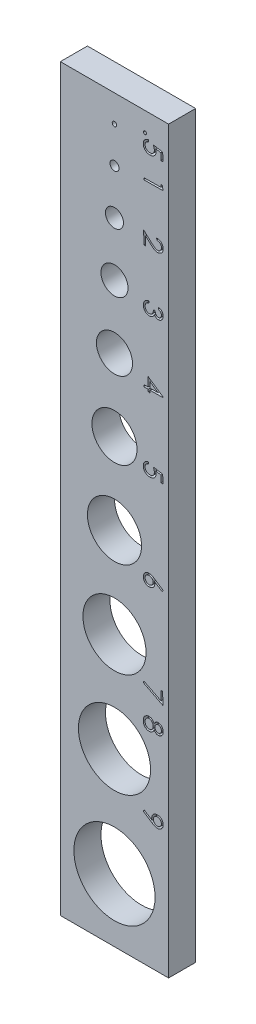
from build123d import *

# Parameters (mm, degrees)
SKETCH1_W           = 12
SKETCH1_H           = 82
SKETCH1_R           = 4.5
SKETCH1_R_2         = 4
SKETCH1_R_3         = 3.5
SKETCH1_R_4         = 3
SKETCH1_R_5         = 1
SKETCH1_R_6         = 1.5
SKETCH1_R_7         = 2
SKETCH1_R_8         = 2.5
SKETCH1_R_9         = 0.5
SKETCH1_R_10        = 0.25
BOSS_EXTRUDE1_DEPTH = 3
CUT_EXTRUDE1_DEPTH  = 0.6


with BuildPart() as part:
    # Sketch1 → Boss-Extrude1 (new body)
    with BuildSketch(Plane.XY):
        with Locations((0, 34)):
            Rectangle(SKETCH1_W, SKETCH1_H)
        Circle(SKETCH1_R, mode=Mode.SUBTRACT)
        with Locations((0, 12)):
            Circle(SKETCH1_R_2, mode=Mode.SUBTRACT)
        with Locations((0, 23)):
            Circle(SKETCH1_R_3, mode=Mode.SUBTRACT)
        with Locations((0, 33)):
            Circle(SKETCH1_R_4, mode=Mode.SUBTRACT)
        with Locations((0, 63)):
            Circle(SKETCH1_R_5, mode=Mode.SUBTRACT)
        with Locations((0, 57)):
            Circle(SKETCH1_R_6, mode=Mode.SUBTRACT)
        with Locations((0, 50)):
            Circle(SKETCH1_R_7, mode=Mode.SUBTRACT)
        with Locations((0, 42)):
            Circle(SKETCH1_R_8, mode=Mode.SUBTRACT)
        with Locations((0, 68)):
            Circle(SKETCH1_R_9, mode=Mode.SUBTRACT)
        with Locations((0, 72)):
            Circle(SKETCH1_R_10, mode=Mode.SUBTRACT)
    extrude(amount=BOSS_EXTRUDE1_DEPTH)

    # Sketch3 → Cut-Extrude1 (cut)
    with BuildSketch(Plane.XY.offset(3)):
        with BuildLine():
            add(Edge.make_bspline(
                [(3.559985776, 72.864336472), (3.559473654, 72.852540956), (3.558469167, 72.829404986), (3.548800443, 72.796162225), (3.532618476, 72.765595711), (3.510294682, 72.738684734), (3.483776229, 72.715488813), (3.453269236, 72.698742779), (3.419548861, 72.688631973), (3.396104516, 72.68706116), (3.384020899, 72.686251536)],
                knots=[0, 0, 0, 0, 1.01541589, 1.991657755, 2.956876933, 3.979293763, 4.990823792, 5.978341565, 6.958002585, 8, 8, 8, 8], degree=3))
            add(Edge.make_bspline(
                [(3.384020899, 72.686251536), (3.372229175, 72.686769628), (3.349100643, 72.687785825), (3.315618284, 72.697423075), (3.285192003, 72.714035693), (3.257793743, 72.735888634), (3.234866364, 72.762415329), (3.218108018, 72.792587334), (3.207383796, 72.825618026), (3.205864975, 72.848707637), (3.20508794, 72.860520366)],
                knots=[0, 0, 0, 0, 1.019769678, 2.000197364, 2.986113415, 4.005221454, 5.021088609, 6.00212763, 6.977881296, 8, 8, 8, 8], degree=3))
            add(Edge.make_bspline(
                [(3.20508794, 72.860520366), (3.205610705, 72.872309948), (3.206636068, 72.895434278), (3.216171942, 72.928826326), (3.232983251, 72.959121398), (3.255175242, 72.986343404), (3.2821235, 73.009248003), (3.312525771, 73.026009756), (3.345778443, 73.036294028), (3.368824174, 73.03754203), (3.380628805, 73.03818129)],
                knots=[0, 0, 0, 0, 1.018230738, 1.997178855, 2.970846284, 3.996097369, 5.019743876, 6.00999916, 6.980669146, 8, 8, 8, 8], degree=3))
            add(Edge.make_bspline(
                [(3.380628805, 73.03818129), (3.392689679, 73.037623738), (3.416173611, 73.036538119), (3.450248233, 73.027633127), (3.480679543, 73.010904306), (3.50773339, 72.988829099), (3.530605666, 72.962444361), (3.54750724, 72.932346215), (3.557557879, 72.899155801), (3.559163067, 72.876135235), (3.559985776, 72.864336472)],
                knots=[0, 0, 0, 0, 1.041595867, 2.028108969, 3.011593627, 4.01868078, 5.03204268, 6.010662336, 6.980401968, 8, 8, 8, 8], degree=3))
        make_face()
        with BuildLine():
            Line((5.360339676, 71.071190772), (5.159782117, 71.069070713))
            Line((5.159782117, 71.069070713), (5.152149906, 71.819147503))
            Line((5.152149906, 71.819147503), (4.57718997, 71.917518229))
            add(Edge.make_bspline(
                [(4.57718997, 71.917518229), (4.583572299, 71.895261787), (4.595886537, 71.852319603), (4.608840583, 71.78867106), (4.618099968, 71.728534577), (4.619391053, 71.689289995), (4.620015157, 71.670319378)],
                knots=[0, 0, 0, 0, 1.103560417, 2.129239359, 3.095684503, 4, 4, 4, 4], degree=3))
            add(Edge.make_bspline(
                [(4.620015157, 71.670319378), (4.619795844, 71.646828608), (4.619366218, 71.600810955), (4.610433662, 71.533252192), (4.59623696, 71.468740358), (4.5758027, 71.407128418), (4.549000115, 71.348862634), (4.515910986, 71.29375656), (4.477352857, 71.241456762), (4.432922749, 71.192962813), (4.383838098, 71.148851338), (4.330786201, 71.110306344), (4.274391197, 71.077167989), (4.214342277, 71.050713248), (4.151150207, 71.029140071), (4.084343076, 71.014083045), (4.014082673, 71.004631966), (3.966077545, 71.002939807), (3.941596353, 71.002076856)],
                knots=[0, 0, 0, 0, 1.055584942, 2.067856546, 3.057852866, 4.02263537, 4.981074008, 5.935965363, 6.908463748, 7.898256009, 8.888497145, 9.871243948, 10.842557664, 11.824152746, 12.817082878, 13.840882629, 14.898914155, 16, 16, 16, 16], degree=3))
            add(Edge.make_bspline(
                [(3.941596353, 71.002076856), (3.924482948, 71.002095453), (3.890481988, 71.002132402), (3.840125962, 71.006837637), (3.790608147, 71.013221189), (3.742316169, 71.023812543), (3.694675593, 71.036118507), (3.648560801, 71.052587907), (3.603192379, 71.071100487), (3.559439816, 71.093238557), (3.517216351, 71.117475196), (3.477613843, 71.144539125), (3.440057838, 71.173206592), (3.405504863, 71.204719853), (3.373011753, 71.237814972), (3.343194042, 71.273309906), (3.315733707, 71.310777384), (3.29104409, 71.350519901), (3.26895593, 71.391972266), (3.249952178, 71.435437908), (3.233374874, 71.480275849), (3.219673571, 71.526860739), (3.209207336, 71.57505727), (3.201569823, 71.624759969), (3.196881508, 71.67602881), (3.195857339, 71.710732418), (3.195335669, 71.728408988)],
                knots=[0, 0, 0, 0, 1.054987957, 2.096052855, 3.116882366, 4.132487153, 5.143291418, 6.149612156, 7.150138838, 8.163796155, 9.171588482, 10.150848618, 11.120359196, 12.083262616, 13.032653721, 13.979198791, 14.939968832, 15.895464126, 16.862620186, 17.834518678, 18.819157809, 19.809492103, 20.826928595, 21.858901691, 22.909413833, 24, 24, 24, 24], degree=3))
            add(Edge.make_bspline(
                [(3.195335669, 71.728408988), (3.195522252, 71.749346634), (3.195890172, 71.790633379), (3.202949564, 71.851188956), (3.214287503, 71.909406256), (3.230811592, 71.965107392), (3.25259468, 72.018267445), (3.279042301, 72.069137026), (3.310384881, 72.11744664), (3.346638493, 72.162840586), (3.386498892, 72.205002572), (3.430058652, 72.24290138), (3.476267263, 72.276473296), (3.52551215, 72.305610981), (3.577706825, 72.330059369), (3.632840783, 72.350552349), (3.690821736, 72.366848981), (3.7309281, 72.373687729), (3.751215077, 72.377146969)],
                knots=[0, 0, 0, 0, 1.070972595, 2.111840699, 3.114818353, 4.103530266, 5.080101137, 6.050733228, 7.033872496, 8.022372693, 9.020119659, 9.999339207, 10.97311987, 11.939537908, 12.923235862, 13.918882858, 14.94730986, 16, 16, 16, 16], degree=3))
            Line((3.751215077, 72.377146969), (3.753335135, 72.160900975))
            add(Edge.make_bspline(
                [(3.753335135, 72.160900975), (3.733996609, 72.156359076), (3.696622026, 72.14758118), (3.644389364, 72.128298406), (3.597402008, 72.105546412), (3.556266979, 72.077683281), (3.520126776, 72.045136248), (3.487557759, 72.008483177), (3.459173004, 71.966603954), (3.435021213, 71.920727656), (3.414716195, 71.87238208), (3.401612575, 71.821789724), (3.392306417, 71.770307544), (3.391871736, 71.73537716), (3.391653111, 71.717808694)],
                knots=[0, 0, 0, 0, 1.144989025, 2.212861912, 3.204660976, 4.149923952, 5.068073888, 6.003830099, 6.971748136, 7.978449302, 8.991371539, 9.988218299, 10.988161226, 12, 12, 12, 12], degree=3))
            add(Edge.make_bspline(
                [(3.391653111, 71.717808694), (3.392265248, 71.700814861), (3.393475986, 71.667203005), (3.401840487, 71.617916411), (3.414605756, 71.570487598), (3.431926236, 71.524868505), (3.454683119, 71.481275841), (3.482489198, 71.439689769), (3.514765638, 71.399591644), (3.551926899, 71.362190008), (3.592670273, 71.328113774), (3.636300159, 71.298244289), (3.682091488, 71.272506916), (3.730715618, 71.252292121), (3.78151493, 71.236425502), (3.834776769, 71.225512308), (3.890407191, 71.218985237), (3.928292637, 71.218545943), (3.947532518, 71.21832285)],
                knots=[0, 0, 0, 0, 0.979540268, 1.937418442, 2.874409727, 3.808170793, 4.744878549, 5.703172589, 6.688222488, 7.708148336, 8.737955377, 9.746060629, 10.752847579, 11.760821078, 12.776342588, 13.816766973, 14.891259097, 16, 16, 16, 16], degree=3))
            add(Edge.make_bspline(
                [(3.947532518, 71.21832285), (3.964939593, 71.218854068), (3.999038878, 71.219894689), (4.048733449, 71.226778907), (4.095887191, 71.237815327), (4.140408443, 71.253187007), (4.182856137, 71.272150966), (4.222228783, 71.296058757), (4.259086181, 71.323989702), (4.293399886, 71.355602335), (4.324138567, 71.391094212), (4.351028379, 71.42944038), (4.373722873, 71.470481178), (4.391981388, 71.514435581), (4.405962111, 71.561203905), (4.415501473, 71.610783501), (4.421823179, 71.662946417), (4.421941355, 71.698708822), (4.422001668, 71.71696067)],
                knots=[0, 0, 0, 0, 1.077209627, 2.110180982, 3.098908156, 4.069869628, 5.021126826, 5.970733619, 6.913709901, 7.879337357, 8.852817336, 9.813798029, 10.773025398, 11.749370118, 12.753951102, 13.788402889, 14.871280215, 16, 16, 16, 16], degree=3))
            add(Edge.make_bspline(
                [(4.422001668, 71.71696067), (4.421551661, 71.732949755), (4.420628901, 71.765736073), (4.41420927, 71.815974668), (4.404859881, 71.86860931), (4.392178005, 71.923717838), (4.375470265, 71.981135432), (4.354918686, 72.040857072), (4.33132318, 72.103150985), (4.313333775, 72.144995953), (4.304126401, 72.166413128)],
                knots=[0, 0, 0, 0, 0.82039401, 1.682253874, 2.595674679, 3.563349206, 4.582547937, 5.662859499, 6.803800105, 8, 8, 8, 8], degree=3))
            Line((4.304126401, 72.166413128), (5.351011417, 71.982816039))
            Line((5.351011417, 71.982816039), (5.360339676, 71.071190772))
        make_face()
        Polygon((5.351011417, 68.71368543), (5.355675547, 68.29984996), (3.250457197, 68.277801349), (3.247913127, 68.486839143), (5.147061765, 68.506767695), (5.143669671, 68.837496862), align=None)
        with BuildLine():
            Line((4.689129072, 63.211284923), (4.687009013, 63.413114517))
            add(Edge.make_bspline(
                [(4.687009013, 63.413114517), (4.712492521, 63.412199779), (4.762544927, 63.410403135), (4.835663206, 63.399237858), (4.905652955, 63.383541302), (4.972041819, 63.360807154), (5.035048837, 63.332457165), (5.094553676, 63.297728467), (5.150427802, 63.256992681), (5.20248725, 63.210804629), (5.249736019, 63.160347227), (5.291080338, 63.106142114), (5.326528274, 63.049173474), (5.355649741, 62.988946547), (5.377916254, 62.925559241), (5.394670092, 62.859334882), (5.404991425, 62.790135934), (5.406593297, 62.742928), (5.40740498, 62.719007278)],
                knots=[0, 0, 0, 0, 1.097505228, 2.155620766, 3.180481467, 4.183502039, 5.172531654, 6.151940074, 7.14558685, 8.146110156, 9.145410305, 10.118288251, 11.077875388, 12.030874005, 12.993642263, 13.966672578, 14.96969315, 16, 16, 16, 16], degree=3))
            add(Edge.make_bspline(
                [(5.40740498, 62.719007278), (5.407144846, 62.695379427), (5.406635389, 62.6491057), (5.398303006, 62.581251674), (5.384545262, 62.516716439), (5.364470271, 62.455607705), (5.338533834, 62.397987217), (5.306450823, 62.3439857), (5.268996711, 62.292965771), (5.225454537, 62.246503594), (5.178092768, 62.204395419), (5.128592174, 62.166793423), (5.076610485, 62.13519053), (5.022205379, 62.109650621), (4.965866449, 62.08928838), (4.9072796, 62.074226418), (4.846568528, 62.065281213), (4.805337082, 62.063805661), (4.784531716, 62.063061098)],
                knots=[0, 0, 0, 0, 1.121975871, 2.197322375, 3.241843777, 4.252685748, 5.247518712, 6.237990346, 7.231893591, 8.248784834, 9.257080656, 10.240217477, 11.198428951, 12.141675047, 13.091211108, 14.040770916, 15.011374074, 16, 16, 16, 16], degree=3))
            add(Edge.make_bspline(
                [(4.784531716, 62.063061098), (4.755063107, 62.063659044), (4.696697855, 62.06484333), (4.610525803, 62.080989198), (4.527074025, 62.106843297), (4.459225435, 62.137510176), (4.405010353, 62.169441863), (4.359901169, 62.197541504), (4.312231496, 62.232019186), (4.260335061, 62.270537878), (4.204881008, 62.314194734), (4.146138855, 62.36307198), (4.083500557, 62.416449863), (4.041419083, 62.454590092), (4.019614516, 62.474352497)],
                knots=[0, 0, 0, 0, 1.188659153, 2.354247174, 3.525968885, 4.71123792, 5.350572219, 6.066366127, 6.856666887, 7.725444904, 8.67666411, 9.706437064, 10.811587574, 12, 12, 12, 12], degree=3))
            Line((4.019614516, 62.474352497), (3.448894697, 62.992070847))
            Line((3.448894697, 62.992070847), (3.459070979, 62.020235911))
            Line((3.459070979, 62.020235911), (3.25596935, 62.018115852))
            Line((3.25596935, 62.018115852), (3.241128939, 63.44788348))
            Line((3.241128939, 63.44788348), (4.118409254, 62.652437433))
            add(Edge.make_bspline(
                [(4.118409254, 62.652437433), (4.1397332, 62.633196124), (4.18068141, 62.596247185), (4.239933208, 62.543350475), (4.2955553, 62.496375087), (4.346792036, 62.454474321), (4.39333777, 62.417406314), (4.435714882, 62.385724611), (4.474288618, 62.360048201), (4.51896422, 62.332174491), (4.573556354, 62.305773276), (4.640115562, 62.282993365), (4.708489629, 62.269274149), (4.754648695, 62.268048233), (4.777747528, 62.267434762)],
                knots=[0, 0, 0, 0, 1.320781117, 2.536285893, 3.652249599, 4.66835783, 5.579870562, 6.388409538, 7.100439732, 7.710169797, 8.808929471, 9.87974959, 10.938988219, 12, 12, 12, 12], degree=3))
            add(Edge.make_bspline(
                [(4.777747528, 62.267434762), (4.792335951, 62.267956412), (4.82110416, 62.2689851), (4.863231445, 62.276156372), (4.904043654, 62.286497755), (4.94274092, 62.302063724), (4.98038961, 62.320700057), (5.015823346, 62.344424262), (5.050412547, 62.371348862), (5.082289867, 62.402827897), (5.111736633, 62.436781773), (5.137928794, 62.472909193), (5.159448472, 62.511125051), (5.177081413, 62.551025746), (5.190655356, 62.592804188), (5.200359333, 62.636371544), (5.206107101, 62.681820459), (5.206316612, 62.712630315), (5.20642341, 62.728335537)],
                knots=[0, 0, 0, 0, 0.999925116, 1.971841423, 2.92388823, 3.881345835, 4.826212886, 5.799288192, 6.799776752, 7.827815551, 8.865358063, 9.879321666, 10.881873478, 11.866892925, 12.866019285, 13.888837022, 14.923841643, 16, 16, 16, 16], degree=3))
            add(Edge.make_bspline(
                [(5.20642341, 62.728335537), (5.205884047, 62.744754108), (5.204819337, 62.777164656), (5.19792196, 62.824597871), (5.18694147, 62.869934964), (5.171474124, 62.912867936), (5.152494402, 62.954028294), (5.128575389, 62.992518079), (5.100651172, 63.028929776), (5.06902234, 63.063176517), (5.033476821, 63.094600045), (4.994092536, 63.122199401), (4.951599955, 63.146548026), (4.905451252, 63.166790418), (4.856273061, 63.183781631), (4.803647633, 63.196957998), (4.747610784, 63.206215598), (4.708945865, 63.209567159), (4.689129072, 63.211284923)],
                knots=[0, 0, 0, 0, 1.000324658, 1.974658513, 2.914587732, 3.837998796, 4.751071336, 5.671264089, 6.592785758, 7.543463651, 8.507543491, 9.477643496, 10.468918963, 11.486736481, 12.543450846, 13.635848679, 14.78830998, 16, 16, 16, 16], degree=3))
        make_face()
        with BuildLine():
            Line((4.861701855, 56.651399105), (4.859157785, 56.866373064))
            add(Edge.make_bspline(
                [(4.859157785, 56.866373064), (4.880436879, 56.861444152), (4.921970126, 56.851823737), (4.981824936, 56.832593521), (5.037754482, 56.809499206), (5.090494812, 56.783989509), (5.139152148, 56.754374239), (5.18425187, 56.721788551), (5.225606747, 56.685625583), (5.262781746, 56.646062145), (5.296424673, 56.604293746), (5.325215504, 56.559950386), (5.350034436, 56.513919186), (5.370555343, 56.465872697), (5.38612071, 56.415654578), (5.397529634, 56.363745774), (5.405090997, 56.310005692), (5.40606329, 56.273488951), (5.406556957, 56.254948117)],
                knots=[0, 0, 0, 0, 1.173306688, 2.290099197, 3.373202571, 4.422689437, 5.434686452, 6.429671004, 7.409144712, 8.381497029, 9.343383221, 10.28704873, 11.218038754, 12.150421619, 13.089584196, 14.038521706, 15.004088426, 16, 16, 16, 16], degree=3))
            add(Edge.make_bspline(
                [(5.406556957, 56.254948117), (5.405965115, 56.227898578), (5.404795728, 56.174452889), (5.391138901, 56.095505638), (5.368210139, 56.019325398), (5.335947567, 55.946672706), (5.296254903, 55.879248905), (5.249054781, 55.819076523), (5.195301276, 55.766768197), (5.13515833, 55.723483586), (5.071438637, 55.688715047), (5.0054749, 55.663357643), (4.937787409, 55.64736982), (4.891891392, 55.645089166), (4.868910055, 55.643947182)],
                knots=[0, 0, 0, 0, 1.077726037, 2.129419264, 3.183224812, 4.243087324, 5.291876736, 6.295389808, 7.283912331, 8.272643719, 9.24111859, 10.170628242, 11.083985668, 12, 12, 12, 12], degree=3))
            add(Edge.make_bspline(
                [(4.868910055, 55.643947182), (4.846796644, 55.644397634), (4.803332941, 55.645282994), (4.740030405, 55.658279188), (4.679985624, 55.678553501), (4.623332068, 55.707765713), (4.570611116, 55.745917246), (4.521369106, 55.792516864), (4.47540958, 55.847234249), (4.449098541, 55.888555941), (4.435570044, 55.909802551)],
                knots=[0, 0, 0, 0, 0.991619515, 1.949018852, 2.888551481, 3.831167361, 4.80011465, 5.801621388, 6.869647158, 8, 8, 8, 8], degree=3))
            add(Edge.make_bspline(
                [(4.435570044, 55.909802551), (4.425084084, 55.88514096), (4.404468127, 55.836654959), (4.362192553, 55.770775203), (4.314628564, 55.710315373), (4.276806533, 55.676238024), (4.25790912, 55.659211605)],
                knots=[0, 0, 0, 0, 1.034722232, 2.034319016, 3.017866478, 4, 4, 4, 4], degree=3))
            add(Edge.make_bspline(
                [(4.25790912, 55.659211605), (4.243939355, 55.648107564), (4.216461747, 55.626266648), (4.172837021, 55.597646801), (4.128036776, 55.573446643), (4.081678247, 55.553829993), (4.034211382, 55.538076138), (3.985425718, 55.526548234), (3.935279476, 55.519736521), (3.901476272, 55.518312802), (3.884354767, 55.51759168)],
                knots=[0, 0, 0, 0, 1.050262654, 2.065797339, 3.067324926, 4.044175813, 5.025729501, 6.008728387, 6.991410217, 8, 8, 8, 8], degree=3))
            add(Edge.make_bspline(
                [(3.884354767, 55.51759168), (3.854730777, 55.518428833), (3.795689348, 55.520097303), (3.708448276, 55.53799134), (3.623215716, 55.566588217), (3.541075692, 55.606712719), (3.464363606, 55.657087667), (3.395628131, 55.717067857), (3.336311972, 55.786008325), (3.286309595, 55.862871796), (3.246208942, 55.946477238), (3.218073553, 56.036039841), (3.19946632, 56.130237073), (3.197008711, 56.194931672), (3.195759681, 56.227811365)],
                knots=[0, 0, 0, 0, 0.966694564, 1.92664895, 2.896261802, 3.897893656, 4.904558281, 5.886300644, 6.86849902, 7.866238128, 8.874183463, 9.887666857, 10.926450323, 12, 12, 12, 12], degree=3))
            add(Edge.make_bspline(
                [(3.195759681, 56.227811365), (3.195934852, 56.250021023), (3.196278278, 56.293563552), (3.203425064, 56.357489561), (3.214657201, 56.418819987), (3.231162383, 56.477492438), (3.252932595, 56.533203709), (3.279319569, 56.586244413), (3.310848334, 56.636257668), (3.346863979, 56.683681368), (3.388308652, 56.727159936), (3.43364498, 56.767950081), (3.484545623, 56.803874367), (3.539790475, 56.836094399), (3.599500739, 56.86457286), (3.663798056, 56.88930292), (3.73298957, 56.909419773), (3.780970437, 56.919936611), (3.805488581, 56.925310697)],
                knots=[0, 0, 0, 0, 1.046149723, 2.050999747, 3.026929888, 3.982181198, 4.918596996, 5.842082274, 6.769881807, 7.701166001, 8.64362752, 9.596762996, 10.57089557, 11.573977735, 12.607839967, 13.685330975, 14.817207988, 16, 16, 16, 16], degree=3))
            Line((3.805488581, 56.925310697), (3.80760864, 56.719240986))
            add(Edge.make_bspline(
                [(3.80760864, 56.719240986), (3.791168254, 56.71444058), (3.759193187, 56.705104223), (3.713251449, 56.689044778), (3.6709446, 56.671278964), (3.63203517, 56.652212387), (3.596857153, 56.631533126), (3.565329809, 56.60931554), (3.536876357, 56.586128858), (3.520520347, 56.568758219), (3.51249646, 56.560236579)],
                knots=[0, 0, 0, 0, 1.209971331, 2.353285215, 3.43640071, 4.450177468, 5.412687175, 6.315866345, 7.173802289, 8, 8, 8, 8], degree=3))
            add(Edge.make_bspline(
                [(3.51249646, 56.560236579), (3.503341082, 56.549115164), (3.485131542, 56.526995288), (3.462235104, 56.490428016), (3.442720356, 56.451988803), (3.426943942, 56.411194877), (3.414569018, 56.368369209), (3.406289615, 56.323051847), (3.400962637, 56.275712882), (3.400693782, 56.243373357), (3.400557357, 56.226963341)],
                knots=[0, 0, 0, 0, 0.960555306, 1.910491269, 2.872342621, 3.834055196, 4.825292892, 5.842842975, 6.905395783, 8, 8, 8, 8], degree=3))
            add(Edge.make_bspline(
                [(3.400557357, 56.226963341), (3.401028536, 56.208277058), (3.401949549, 56.171750955), (3.409641819, 56.118638213), (3.420189694, 56.068207202), (3.43633712, 56.020990191), (3.455509212, 55.976062192), (3.480022698, 55.93453567), (3.508152782, 55.895396297), (3.540653007, 55.859792216), (3.57594697, 55.827787703), (3.613213571, 55.800155425), (3.651342247, 55.776020509), (3.691356564, 55.756878149), (3.732853366, 55.742592975), (3.775465479, 55.731663118), (3.819734875, 55.72574634), (3.849711076, 55.725206212), (3.864850226, 55.724933427)],
                knots=[0, 0, 0, 0, 1.173759928, 2.29435017, 3.367680958, 4.407023928, 5.425313666, 6.432383096, 7.430954561, 8.449747856, 9.455994245, 10.420684121, 11.362276694, 12.288023167, 13.201067594, 14.116700998, 15.048860564, 16, 16, 16, 16], degree=3))
            add(Edge.make_bspline(
                [(3.864850226, 55.724933427), (3.885139781, 55.726011884), (3.925458589, 55.728154963), (3.984575589, 55.742351397), (4.041652165, 55.764488776), (4.095503118, 55.795601744), (4.145440568, 55.833317337), (4.189103928, 55.878039092), (4.226318373, 55.928270552), (4.251180665, 55.975284711), (4.268115632, 56.016563343), (4.278824036, 56.052176293), (4.289174738, 56.09140666), (4.297378659, 56.134803918), (4.30462847, 56.18203468), (4.310429864, 56.233245268), (4.315143962, 56.28852865), (4.317103619, 56.326739897), (4.318118789, 56.346534656)],
                knots=[0, 0, 0, 0, 1.127643216, 2.240819507, 3.362973506, 4.520875543, 5.687040538, 6.831721848, 7.983742915, 9.150887069, 9.778347085, 10.461812224, 11.216548265, 12.033326562, 12.915734579, 13.872895481, 14.898085661, 16, 16, 16, 16], degree=3))
            Line((4.318118789, 56.346534656), (4.511044136, 56.348654714))
            add(Edge.make_bspline(
                [(4.511044136, 56.348654714), (4.511825846, 56.325011341), (4.513354538, 56.278774981), (4.523941232, 56.211034024), (4.54022386, 56.146594931), (4.562899639, 56.086285567), (4.590814008, 56.032114191), (4.621309622, 55.98425943), (4.656487512, 55.945305375), (4.694581971, 55.913998678), (4.735766926, 55.891420991), (4.778159643, 55.874173537), (4.822707837, 55.864833114), (4.852900263, 55.863720154), (4.868062032, 55.863161258)],
                knots=[0, 0, 0, 0, 1.268875079, 2.481378802, 3.671964755, 4.831691112, 5.931079786, 6.939043712, 7.86841796, 8.736960605, 9.572638348, 10.379936968, 11.186450867, 12, 12, 12, 12], degree=3))
            add(Edge.make_bspline(
                [(4.868062032, 55.863161258), (4.879396514, 55.863596325), (4.90163387, 55.864449892), (4.934238273, 55.870384881), (4.965933014, 55.878632529), (4.996356467, 55.891001001), (5.025468986, 55.906859054), (5.053182163, 55.926220102), (5.079957726, 55.94869145), (5.105118772, 55.974470442), (5.128530088, 56.002559791), (5.148332142, 56.033352362), (5.165515411, 56.06558157), (5.179013832, 56.099787612), (5.189641347, 56.135542953), (5.1973164, 56.172972112), (5.20167146, 56.212299874), (5.20172955, 56.239107538), (5.201759281, 56.252828058)],
                knots=[0, 0, 0, 0, 0.95166413, 1.867089752, 2.777187475, 3.698751812, 4.617865583, 5.556479832, 6.533937407, 7.549793846, 8.578953447, 9.599792997, 10.619458175, 11.642435756, 12.682969136, 13.74939355, 14.848109587, 16, 16, 16, 16], degree=3))
            add(Edge.make_bspline(
                [(5.201759281, 56.252828058), (5.200636688, 56.27482184), (5.198451575, 56.3176325), (5.183232166, 56.379378577), (5.158265654, 56.436066365), (5.129756045, 56.479419151), (5.101798038, 56.511257767), (5.077333922, 56.534329179), (5.049619914, 56.556353708), (5.018669635, 56.577605555), (4.984078243, 56.597432113), (4.946272106, 56.616499024), (4.905199367, 56.634676076), (4.876451102, 56.645728618), (4.861701855, 56.651399105)],
                knots=[0, 0, 0, 0, 1.404109188, 2.733083474, 4.034611119, 5.344034922, 6.028487238, 6.737270714, 7.488689976, 8.287420331, 9.132790347, 10.033057222, 10.990863469, 12, 12, 12, 12], degree=3))
        make_face()
        Polygon((5.411645098, 48.470092348), (5.41206911, 48.427267161), (3.944988447, 48.412002738), (3.947532518, 48.157171675), (3.745702924, 48.155051616), (3.743158853, 48.409882679), (3.253849291, 48.404794538), (3.251729232, 48.615104367), (3.741038794, 48.620192508), (3.730438501, 49.625948384), align=None)
        Polygon((3.942868388, 48.622312567), (4.820148704, 48.631640825), (3.9360842, 49.241793737), align=None, mode=Mode.SUBTRACT)
        with BuildLine():
            Line((5.360339676, 40.135293336), (5.159782117, 40.133173277))
            Line((5.159782117, 40.133173277), (5.152149906, 40.883250067))
            Line((5.152149906, 40.883250067), (4.57718997, 40.981620793))
            add(Edge.make_bspline(
                [(4.57718997, 40.981620793), (4.583572299, 40.959364351), (4.595886537, 40.916422168), (4.608840583, 40.852773624), (4.618099968, 40.792637141), (4.619391053, 40.753392559), (4.620015157, 40.734421942)],
                knots=[0, 0, 0, 0, 1.103560417, 2.129239359, 3.095684503, 4, 4, 4, 4], degree=3))
            add(Edge.make_bspline(
                [(4.620015157, 40.734421942), (4.619795844, 40.710931172), (4.619366218, 40.664913519), (4.610433662, 40.597354756), (4.59623696, 40.532842922), (4.5758027, 40.471230982), (4.549000115, 40.412965198), (4.515910986, 40.357859124), (4.477352857, 40.305559326), (4.432922749, 40.257065377), (4.383838098, 40.212953903), (4.330786201, 40.174408908), (4.274391197, 40.141270553), (4.214342277, 40.114815812), (4.151150207, 40.093242635), (4.084343076, 40.078185609), (4.014082673, 40.068734531), (3.966077545, 40.067042371), (3.941596353, 40.06617942)],
                knots=[0, 0, 0, 0, 1.055584942, 2.067856546, 3.057852866, 4.02263537, 4.981074008, 5.935965363, 6.908463748, 7.898256009, 8.888497145, 9.871243948, 10.842557664, 11.824152746, 12.817082878, 13.840882629, 14.898914155, 16, 16, 16, 16], degree=3))
            add(Edge.make_bspline(
                [(3.941596353, 40.06617942), (3.924482948, 40.066198018), (3.890481988, 40.066234966), (3.840125962, 40.070940201), (3.790608147, 40.077323753), (3.742316169, 40.087915107), (3.694675593, 40.100221071), (3.648560801, 40.116690471), (3.603192379, 40.135203051), (3.559439816, 40.157341121), (3.517216351, 40.18157776), (3.477613843, 40.208641689), (3.440057838, 40.237309156), (3.405504863, 40.268822417), (3.373011753, 40.301917537), (3.343194042, 40.33741247), (3.315733707, 40.374879948), (3.29104409, 40.414622465), (3.26895593, 40.45607483), (3.249952178, 40.499540472), (3.233374874, 40.544378413), (3.219673571, 40.590963303), (3.209207336, 40.639159834), (3.201569823, 40.688862533), (3.196881508, 40.740131374), (3.195857339, 40.774834982), (3.195335669, 40.792511552)],
                knots=[0, 0, 0, 0, 1.054987957, 2.096052855, 3.116882366, 4.132487153, 5.143291418, 6.149612156, 7.150138838, 8.163796155, 9.171588482, 10.150848618, 11.120359196, 12.083262616, 13.032653721, 13.979198791, 14.939968832, 15.895464126, 16.862620186, 17.834518678, 18.819157809, 19.809492103, 20.826928595, 21.858901691, 22.909413833, 24, 24, 24, 24], degree=3))
            add(Edge.make_bspline(
                [(3.195335669, 40.792511552), (3.195522252, 40.813449198), (3.195890172, 40.854735943), (3.202949564, 40.91529152), (3.214287503, 40.97350882), (3.230811592, 41.029209956), (3.25259468, 41.082370009), (3.279042301, 41.13323959), (3.310384881, 41.181549204), (3.346638493, 41.22694315), (3.386498892, 41.269105136), (3.430058652, 41.307003944), (3.476267263, 41.34057586), (3.52551215, 41.369713545), (3.577706825, 41.394161933), (3.632840783, 41.414654913), (3.690821736, 41.430951546), (3.7309281, 41.437790293), (3.751215077, 41.441249533)],
                knots=[0, 0, 0, 0, 1.070972595, 2.111840699, 3.114818353, 4.103530266, 5.080101137, 6.050733228, 7.033872496, 8.022372693, 9.020119659, 9.999339207, 10.97311987, 11.939537908, 12.923235862, 13.918882858, 14.94730986, 16, 16, 16, 16], degree=3))
            Line((3.751215077, 41.441249533), (3.753335135, 41.225003539))
            add(Edge.make_bspline(
                [(3.753335135, 41.225003539), (3.733996609, 41.22046164), (3.696622026, 41.211683744), (3.644389364, 41.19240097), (3.597402008, 41.169648977), (3.556266979, 41.141785845), (3.520126776, 41.109238812), (3.487557759, 41.072585742), (3.459173004, 41.030706518), (3.435021213, 40.98483022), (3.414716195, 40.936484644), (3.401612575, 40.885892288), (3.392306417, 40.834410108), (3.391871736, 40.799479724), (3.391653111, 40.781911258)],
                knots=[0, 0, 0, 0, 1.144989025, 2.212861912, 3.204660976, 4.149923952, 5.068073888, 6.003830099, 6.971748136, 7.978449302, 8.991371539, 9.988218299, 10.988161226, 12, 12, 12, 12], degree=3))
            add(Edge.make_bspline(
                [(3.391653111, 40.781911258), (3.392265248, 40.764917425), (3.393475986, 40.731305569), (3.401840487, 40.682018975), (3.414605756, 40.634590162), (3.431926236, 40.588971069), (3.454683119, 40.545378405), (3.482489198, 40.503792333), (3.514765638, 40.463694208), (3.551926899, 40.426292573), (3.592670273, 40.392216338), (3.636300159, 40.362346853), (3.682091488, 40.33660948), (3.730715618, 40.316394685), (3.78151493, 40.300528066), (3.834776769, 40.289614872), (3.890407191, 40.283087801), (3.928292637, 40.282648507), (3.947532518, 40.282425414)],
                knots=[0, 0, 0, 0, 0.979540268, 1.937418442, 2.874409727, 3.808170793, 4.744878549, 5.703172589, 6.688222488, 7.708148336, 8.737955377, 9.746060629, 10.752847579, 11.760821078, 12.776342588, 13.816766973, 14.891259097, 16, 16, 16, 16], degree=3))
            add(Edge.make_bspline(
                [(3.947532518, 40.282425414), (3.964939593, 40.282956632), (3.999038878, 40.283997253), (4.048733449, 40.290881471), (4.095887191, 40.301917892), (4.140408443, 40.317289571), (4.182856137, 40.33625353), (4.222228783, 40.360161321), (4.259086181, 40.388092266), (4.293399886, 40.419704899), (4.324138567, 40.455196777), (4.351028379, 40.493542944), (4.373722873, 40.534583742), (4.391981388, 40.578538145), (4.405962111, 40.625306469), (4.415501473, 40.674886065), (4.421823179, 40.727048981), (4.421941355, 40.762811386), (4.422001668, 40.781063235)],
                knots=[0, 0, 0, 0, 1.077209627, 2.110180982, 3.098908156, 4.069869628, 5.021126826, 5.970733619, 6.913709901, 7.879337357, 8.852817336, 9.813798029, 10.773025398, 11.749370118, 12.753951102, 13.788402889, 14.871280215, 16, 16, 16, 16], degree=3))
            add(Edge.make_bspline(
                [(4.422001668, 40.781063235), (4.421551661, 40.797052319), (4.420628901, 40.829838637), (4.41420927, 40.880077232), (4.404859881, 40.932711874), (4.392178005, 40.987820402), (4.375470265, 41.045237996), (4.354918686, 41.104959636), (4.33132318, 41.167253549), (4.313333775, 41.209098517), (4.304126401, 41.230515692)],
                knots=[0, 0, 0, 0, 0.82039401, 1.682253874, 2.595674679, 3.563349206, 4.582547937, 5.662859499, 6.803800105, 8, 8, 8, 8], degree=3))
            Line((4.304126401, 41.230515692), (5.351011417, 41.046918603))
            Line((5.351011417, 41.046918603), (5.360339676, 40.135293336))
        make_face()
        with BuildLine():
            Line((5.409525039, 29.918730168), (5.29843396, 29.744461338))
            Line((5.29843396, 29.744461338), (4.430905915, 30.303732839))
            add(Edge.make_bspline(
                [(4.430905915, 30.303732839), (4.436986182, 30.285158351), (4.448892527, 30.24878589), (4.461507081, 30.19419487), (4.469527611, 30.141286305), (4.470926242, 30.106593343), (4.471611043, 30.089606904)],
                knots=[0, 0, 0, 0, 1.07113288, 2.097486466, 3.068487418, 4, 4, 4, 4], degree=3))
            add(Edge.make_bspline(
                [(4.471611043, 30.089606904), (4.471345443, 30.069084729), (4.470821204, 30.028578275), (4.462409463, 29.969074227), (4.448937316, 29.911948128), (4.429657547, 29.857057317), (4.404570315, 29.804518731), (4.373928312, 29.754074609), (4.337025269, 29.706504125), (4.295366146, 29.661478813), (4.249732097, 29.620161294), (4.200492738, 29.584429918), (4.149114049, 29.553597569), (4.094747838, 29.528558828), (4.037801891, 29.508267831), (3.977825496, 29.494772726), (3.915457547, 29.48533917), (3.872942677, 29.48396846), (3.85128185, 29.483270099)],
                knots=[0, 0, 0, 0, 1.018280883, 2.009872138, 2.976790137, 3.929052543, 4.892832391, 5.86300533, 6.854074845, 7.877181731, 8.905930242, 9.905438123, 10.893645607, 11.876479981, 12.873125352, 13.889469418, 14.924709423, 16, 16, 16, 16], degree=3))
            add(Edge.make_bspline(
                [(3.85128185, 29.483270099), (3.821683752, 29.483919411), (3.76336454, 29.485198798), (3.677963686, 29.500280346), (3.597138993, 29.526545701), (3.520875706, 29.56244835), (3.450969225, 29.608805317), (3.387722429, 29.664235967), (3.332082362, 29.728657298), (3.284282794, 29.801021723), (3.245995503, 29.879486229), (3.217710433, 29.961883427), (3.200232601, 30.047472127), (3.197541138, 30.105639376), (3.196183693, 30.134976162)],
                knots=[0, 0, 0, 0, 1.033374691, 2.036130795, 3.016962388, 3.995603178, 4.972248063, 5.938144807, 6.92542083, 7.937679075, 8.96032944, 9.967696499, 10.975003024, 12, 12, 12, 12], degree=3))
            add(Edge.make_bspline(
                [(3.196183693, 30.134976162), (3.196821859, 30.163312808), (3.198088256, 30.219544895), (3.213631819, 30.302170715), (3.238536706, 30.382045429), (3.274930271, 30.457601297), (3.319745183, 30.52857989), (3.374665547, 30.59164154), (3.437621001, 30.647180194), (3.508839087, 30.693199525), (3.585229151, 30.730906418), (3.66532872, 30.758764292), (3.748536112, 30.775747672), (3.804987692, 30.778506116), (3.833473356, 30.779898037)],
                knots=[0, 0, 0, 0, 1.009186099, 2.002659077, 2.986059601, 3.98469603, 4.984247613, 5.970369082, 6.956001077, 7.968001925, 8.984485162, 9.986967225, 10.984216614, 12, 12, 12, 12], degree=3))
            add(Edge.make_bspline(
                [(3.833473356, 30.779898037), (3.855272216, 30.779513588), (3.899634787, 30.7787312), (3.966875496, 30.768722887), (4.035752009, 30.752955836), (4.094141957, 30.73471515), (4.142313926, 30.716186211), (4.18068899, 30.69957545), (4.221283349, 30.680946512), (4.263464784, 30.65924364), (4.307587949, 30.635083607), (4.353430473, 30.608184745), (4.40131112, 30.579080124), (4.433501406, 30.558221535), (4.449986444, 30.547539597)],
                knots=[0, 0, 0, 0, 1.172854459, 2.386860531, 3.651453688, 4.975272331, 5.676275456, 6.429720153, 7.226464736, 8.080737454, 8.983272135, 9.934786162, 10.942378808, 12, 12, 12, 12], degree=3))
            Line((4.449986444, 30.547539597), (5.409525039, 29.918730168))
        make_face()
        with BuildLine():
            add(Edge.make_bspline(
                [(4.286741919, 30.137944244), (4.286168606, 30.152947252), (4.28503857, 30.182519069), (4.278613157, 30.226015396), (4.268008473, 30.267805364), (4.25314197, 30.307721802), (4.234139951, 30.345782638), (4.21185667, 30.382433045), (4.184642702, 30.416967737), (4.154102841, 30.449551222), (4.120922793, 30.479544602), (4.085609312, 30.505659601), (4.048290586, 30.527192928), (4.009857705, 30.545877051), (3.96924678, 30.559128731), (3.927319759, 30.569190515), (3.883511196, 30.57463561), (3.853698235, 30.575225083), (3.838561497, 30.575524372)],
                knots=[0, 0, 0, 0, 1.0339263, 2.037929961, 3.022860678, 3.999669711, 4.966524986, 5.950299568, 6.949616574, 7.989989403, 9.024374228, 10.027480128, 11.009566239, 11.989719108, 12.965945435, 13.946243429, 14.957259787, 16, 16, 16, 16], degree=3))
            add(Edge.make_bspline(
                [(3.838561497, 30.575524372), (3.823558177, 30.574951643), (3.793985744, 30.573822759), (3.750493903, 30.567388954), (3.708687352, 30.556815299), (3.668713015, 30.541789886), (3.630426589, 30.523192584), (3.593991296, 30.50034623), (3.559120779, 30.473602418), (3.52655922, 30.44285373), (3.496498718, 30.409729305), (3.470614763, 30.374427148), (3.448604807, 30.337560644), (3.431022559, 30.298943292), (3.416490394, 30.258815596), (3.407625018, 30.216701106), (3.401796821, 30.17316187), (3.401255991, 30.143617842), (3.400981369, 30.128615986)],
                knots=[0, 0, 0, 0, 1.035379192, 2.040793697, 3.027108457, 4.00529012, 4.982255714, 5.959123956, 6.967560851, 8.00939563, 9.045233991, 10.049749474, 11.02481497, 12.002218523, 12.973766386, 13.962777315, 14.965539756, 16, 16, 16, 16], degree=3))
            add(Edge.make_bspline(
                [(3.400981369, 30.128615986), (3.401557197, 30.11361376), (3.402692188, 30.084043484), (3.409081489, 30.040535925), (3.419807534, 29.998834716), (3.434202621, 29.958689793), (3.452856408, 29.920363711), (3.476199552, 29.884156154), (3.502894378, 29.849306786), (3.533219175, 29.816469853), (3.56638337, 29.786591003), (3.601708682, 29.760525688), (3.638877319, 29.738782306), (3.677550997, 29.721057815), (3.717693265, 29.706550121), (3.759803786, 29.697678078), (3.803344093, 29.691851681), (3.832887974, 29.691310605), (3.847889756, 29.691035857)],
                knots=[0, 0, 0, 0, 1.035146541, 2.040335127, 3.02642826, 4.001030843, 4.977776911, 5.959619206, 6.967829503, 8.002792361, 9.038397967, 10.042687733, 11.025932903, 12.003116832, 12.974446386, 13.963235082, 14.965772201, 16, 16, 16, 16], degree=3))
            add(Edge.make_bspline(
                [(3.847889756, 29.691035857), (3.863034546, 29.691602231), (3.892748814, 29.692713463), (3.936520385, 29.699196479), (3.978393509, 29.709790045), (4.018678117, 29.724241077), (4.057036995, 29.743053824), (4.093534354, 29.765976753), (4.128058266, 29.79311938), (4.160906693, 29.82324645), (4.190744137, 29.856450347), (4.216878265, 29.891740555), (4.238423063, 29.929060178), (4.256984806, 29.967391186), (4.270505451, 30.007919779), (4.280291118, 30.04977595), (4.285875149, 30.093411926), (4.286450014, 30.122946956), (4.286741919, 30.137944244)],
                knots=[0, 0, 0, 0, 1.043393225, 2.047150523, 3.041276387, 4.014491233, 4.989846512, 5.97852245, 6.977594245, 8.011083419, 9.045214426, 10.048074184, 11.029919311, 12.00983167, 12.976596784, 13.966135232, 14.967244838, 16, 16, 16, 16], degree=3))
        make_face(mode=Mode.SUBTRACT)
        Polygon((5.347619323, 20.199532786), (5.361611711, 18.864319778), (3.191519564, 19.968022369), (3.278441973, 20.141867188), (5.159358105, 19.188264757), (5.148757812, 20.197412727), align=None)
        with BuildLine():
            add(Edge.make_bspline(
                [(4.407161257, 16.017080863), (4.398591089, 15.999736121), (4.381857138, 15.965869101), (4.354150537, 15.918022381), (4.325779688, 15.873828397), (4.29659688, 15.833257404), (4.265850963, 15.796823314), (4.234770653, 15.763592363), (4.202172204, 15.734505888), (4.16867313, 15.70904075), (4.134064155, 15.686803756), (4.09844152, 15.667734504), (4.061568399, 15.651503424), (4.023681511, 15.637835129), (3.984285734, 15.627785962), (3.9439247, 15.620211218), (3.902308899, 15.614744802), (3.874054991, 15.61414773), (3.859762085, 15.613845686)],
                knots=[0, 0, 0, 0, 1.286588117, 2.512168053, 3.675250502, 4.7791079, 5.833577724, 6.844395225, 7.803156546, 8.735795287, 9.64072854, 10.536630885, 11.420565147, 12.318586108, 13.212463701, 14.121489931, 15.049711372, 16, 16, 16, 16], degree=3))
            add(Edge.make_bspline(
                [(3.859762085, 15.613845686), (3.839813748, 15.614040303), (3.800359097, 15.614425223), (3.742028491, 15.621468), (3.685375168, 15.633257141), (3.630537073, 15.650419348), (3.577232844, 15.672038285), (3.525818058, 15.698823745), (3.476323326, 15.73088817), (3.44517795, 15.755358024), (3.429390157, 15.767761953)],
                knots=[0, 0, 0, 0, 1.024449428, 2.02619875, 3.013308495, 3.994200164, 4.974688446, 5.965451746, 6.968674306, 8, 8, 8, 8], degree=3))
            add(Edge.make_bspline(
                [(3.429390157, 15.767761953), (3.411025367, 15.784307767), (3.37453313, 15.817185561), (3.327239943, 15.873783588), (3.287208453, 15.935624778), (3.254266046, 16.002789763), (3.229025278, 16.075339615), (3.210286931, 16.152992292), (3.198853488, 16.235965636), (3.196808544, 16.293076724), (3.195759681, 16.322369324)],
                knots=[0, 0, 0, 0, 0.95313371, 1.893949347, 2.836597702, 3.79049601, 4.773916428, 5.795334403, 6.869214536, 8, 8, 8, 8], degree=3))
            add(Edge.make_bspline(
                [(3.195759681, 16.322369324), (3.195975534, 16.350660188), (3.196394296, 16.405545557), (3.205111122, 16.485419871), (3.219615308, 16.560176873), (3.240937986, 16.629608303), (3.267966832, 16.694023164), (3.30226973, 16.752708572), (3.342234974, 16.806758099), (3.388588729, 16.854603146), (3.438338557, 16.897229047), (3.49035, 16.933959628), (3.542956324, 16.966334465), (3.597419344, 16.992272157), (3.653364666, 17.012123162), (3.710298076, 17.027246464), (3.768739033, 17.036295809), (3.808143778, 17.037779165), (3.827961204, 17.038525174)],
                knots=[0, 0, 0, 0, 1.268241981, 2.460438488, 3.597990162, 4.678805503, 5.712624759, 6.723806334, 7.720336391, 8.720187788, 9.704811104, 10.654701819, 11.573365278, 12.472217908, 13.354487406, 14.232442043, 15.111060126, 16, 16, 16, 16], degree=3))
            add(Edge.make_bspline(
                [(3.827961204, 17.038525174), (3.842524944, 17.038444888), (3.871282712, 17.038286355), (3.913858045, 17.034537598), (3.955139215, 17.027035086), (3.995591023, 17.017437529), (4.034991201, 17.004666927), (4.073416819, 16.989082164), (4.110249223, 16.969631991), (4.146586008, 16.948050012), (4.182059322, 16.923035305), (4.21593192, 16.893443532), (4.249153302, 16.860097498), (4.281762574, 16.823085247), (4.312597503, 16.781417583), (4.343153819, 16.736528524), (4.373066716, 16.687738744), (4.391117031, 16.653073634), (4.400377069, 16.635289997)],
                knots=[0, 0, 0, 0, 0.940568411, 1.85725972, 2.756368827, 3.648777793, 4.540953211, 5.429383518, 6.32365867, 7.228681816, 8.158420037, 9.122965851, 10.130085124, 11.197671969, 12.306056823, 13.47598145, 14.705146815, 16, 16, 16, 16], degree=3))
            add(Edge.make_bspline(
                [(4.400377069, 16.635289997), (4.413804346, 16.659944784), (4.439762341, 16.707608118), (4.486819176, 16.771427179), (4.538894866, 16.825461821), (4.595625441, 16.869895772), (4.655912108, 16.904814683), (4.718846426, 16.930104237), (4.784168378, 16.94612416), (4.82868071, 16.948357682), (4.851101562, 16.949482706)],
                knots=[0, 0, 0, 0, 1.163120301, 2.248577245, 3.27648082, 4.265989786, 5.227023139, 6.155368436, 7.070859531, 8, 8, 8, 8], degree=3))
            add(Edge.make_bspline(
                [(4.851101562, 16.949482706), (4.873920236, 16.94857371), (4.919868282, 16.946743341), (4.988412599, 16.932049229), (5.055450098, 16.905674431), (5.121323612, 16.870969651), (5.183179973, 16.826453661), (5.240022664, 16.774277702), (5.288234717, 16.712551368), (5.330250646, 16.644777845), (5.363364488, 16.571071102), (5.388312086, 16.493957963), (5.403534912, 16.413413768), (5.405822056, 16.358615997), (5.406980969, 16.330849559)],
                knots=[0, 0, 0, 0, 0.891779735, 1.795701879, 2.724501376, 3.701000045, 4.699287438, 5.696335149, 6.706950829, 7.751402419, 8.80741229, 9.857738879, 10.914500359, 12, 12, 12, 12], degree=3))
            add(Edge.make_bspline(
                [(5.406980969, 16.330849559), (5.406443151, 16.303791207), (5.405382804, 16.250443632), (5.391037162, 16.172003313), (5.368289892, 16.096399614), (5.335637335, 16.024690813), (5.294979894, 15.958377289), (5.247834717, 15.898001861), (5.192566649, 15.846252408), (5.131660744, 15.802055544), (5.066301146, 15.767194598), (4.998568629, 15.741291545), (4.928886905, 15.724981858), (4.881573493, 15.722408851), (4.85788575, 15.72112066)],
                knots=[0, 0, 0, 0, 1.069166932, 2.107942919, 3.1426779, 4.186198553, 5.215176545, 6.21418414, 7.206975739, 8.200192392, 9.183316051, 10.128334002, 11.062939222, 12, 12, 12, 12], degree=3))
            add(Edge.make_bspline(
                [(4.85788575, 15.72112066), (4.834644619, 15.721878591), (4.789044306, 15.723365691), (4.722352853, 15.736822088), (4.659556928, 15.759810411), (4.600772391, 15.792615677), (4.545869501, 15.834693089), (4.495434874, 15.8868291), (4.447916205, 15.947664396), (4.421055599, 15.99341512), (4.407161257, 16.017080863)],
                knots=[0, 0, 0, 0, 0.979772443, 1.922364724, 2.85622095, 3.790457876, 4.751764511, 5.763779242, 6.843257082, 8, 8, 8, 8], degree=3))
        make_face()
        with BuildLine():
            add(Edge.make_bspline(
                [(5.202183292, 16.338905783), (5.201692154, 16.353053186), (5.200731314, 16.380730518), (5.195661313, 16.421341053), (5.18705178, 16.460014082), (5.175783766, 16.497033038), (5.16088733, 16.532019141), (5.142412974, 16.564804466), (5.121137269, 16.595885627), (5.097211785, 16.624889976), (5.070998833, 16.651229766), (5.042983302, 16.673999578), (5.01418072, 16.693693389), (4.984133035, 16.709748698), (4.952549176, 16.721523406), (4.9198613, 16.729938528), (4.886053608, 16.735380942), (4.863136263, 16.735646329), (4.851525573, 16.735780783)],
                knots=[0, 0, 0, 0, 1.152232389, 2.25417474, 3.326391932, 4.374689561, 5.40070557, 6.415625679, 7.433867746, 8.463813013, 9.472844168, 10.454196194, 11.398969984, 12.310134972, 13.220645674, 14.136160615, 15.055716947, 16, 16, 16, 16], degree=3))
            add(Edge.make_bspline(
                [(4.851525573, 16.735780783), (4.839899602, 16.735407843), (4.816894022, 16.734669868), (4.783020221, 16.727680981), (4.749920195, 16.718236209), (4.717627967, 16.704356685), (4.686497205, 16.686513719), (4.655919376, 16.665000762), (4.626517102, 16.63960443), (4.598311608, 16.610948013), (4.572308656, 16.579938741), (4.549202051, 16.547317599), (4.530117688, 16.513112992), (4.514207234, 16.477877346), (4.502387421, 16.441133949), (4.493939706, 16.403243908), (4.488558647, 16.364078435), (4.488285649, 16.337509999), (4.488147502, 16.324065371)],
                knots=[0, 0, 0, 0, 0.920635762, 1.821762709, 2.733075336, 3.64686511, 4.600401803, 5.5735581, 6.606741904, 7.676532589, 8.758405092, 9.812347902, 10.840963443, 11.85933337, 12.872882438, 13.895129539, 14.934856381, 16, 16, 16, 16], degree=3))
            add(Edge.make_bspline(
                [(4.488147502, 16.324065371), (4.488966996, 16.30691451), (4.490599782, 16.272742593), (4.501121878, 16.222414998), (4.517879665, 16.17362168), (4.540531169, 16.126723404), (4.569327441, 16.083485981), (4.602401944, 16.044148336), (4.641220464, 16.011116204), (4.683259631, 15.982797264), (4.727876712, 15.960363718), (4.773418793, 15.944787839), (4.818850617, 15.934658274), (4.849212767, 15.933917383), (4.864245926, 15.933550548)],
                knots=[0, 0, 0, 0, 1.029292353, 2.050794634, 3.072895551, 4.120036331, 5.167039655, 6.183775547, 7.194085661, 8.215200402, 9.220547923, 10.180977383, 11.099350464, 12, 12, 12, 12], degree=3))
            add(Edge.make_bspline(
                [(4.864245926, 15.933550548), (4.874727788, 15.934038929), (4.895664801, 15.935014447), (4.926713547, 15.940406665), (4.957378885, 15.948005768), (4.986667947, 15.960563795), (5.015981864, 15.974724814), (5.044138352, 15.993186349), (5.071770291, 16.01445369), (5.098574031, 16.038562247), (5.123532171, 16.065824332), (5.145234332, 16.096419799), (5.163080027, 16.13003612), (5.178048973, 16.166192165), (5.18939404, 16.205449735), (5.197486873, 16.247445727), (5.201549406, 16.292323163), (5.201967788, 16.323068919), (5.202183292, 16.338905783)],
                knots=[0, 0, 0, 0, 0.853487636, 1.704800381, 2.561694548, 3.418588715, 4.293452282, 5.209572628, 6.153247859, 7.130901113, 8.141062849, 9.156389345, 10.175815821, 11.233618752, 12.336947772, 13.496969187, 14.710711301, 16, 16, 16, 16], degree=3))
        make_face(mode=Mode.SUBTRACT)
        with BuildLine():
            add(Edge.make_bspline(
                [(4.297766225, 16.319401242), (4.297280809, 16.337237871), (4.296329003, 16.372211961), (4.288742774, 16.423409755), (4.277504864, 16.472475579), (4.261291765, 16.519172888), (4.240796619, 16.563603176), (4.216052825, 16.605754606), (4.187087254, 16.645916381), (4.153773415, 16.683193478), (4.117708886, 16.717211099), (4.079875089, 16.747103459), (4.040704699, 16.772293205), (4.000124172, 16.792899627), (3.95788224, 16.808699893), (3.914208902, 16.819593999), (3.869159728, 16.826296135), (3.838726431, 16.826725584), (3.823297074, 16.826943309)],
                knots=[0, 0, 0, 0, 1.108759483, 2.1740574, 3.212360909, 4.235296843, 5.242093767, 6.250615808, 7.27037468, 8.316388102, 9.354803219, 10.350061758, 11.310718067, 12.246276141, 13.175245841, 14.108985368, 15.041275793, 16, 16, 16, 16], degree=3))
            add(Edge.make_bspline(
                [(3.823297074, 16.826943309), (3.804150792, 16.825942058), (3.766176569, 16.823956202), (3.710178867, 16.811134252), (3.656078093, 16.790544038), (3.604054742, 16.762678689), (3.555892362, 16.727810591), (3.513335034, 16.685959615), (3.476586097, 16.638058663), (3.446122586, 16.584092087), (3.422386132, 16.524729871), (3.405489168, 16.460824296), (3.395521214, 16.392508291), (3.394926258, 16.345582572), (3.394621193, 16.321521301)],
                knots=[0, 0, 0, 0, 0.930024942, 1.844586514, 2.77681402, 3.73527427, 4.703522471, 5.655195111, 6.624781429, 7.627193283, 8.656156312, 9.722095485, 10.831999176, 12, 12, 12, 12], degree=3))
            add(Edge.make_bspline(
                [(3.394621193, 16.321521301), (3.395089576, 16.302834554), (3.396005124, 16.266307544), (3.403756331, 16.213064449), (3.414204599, 16.16247704), (3.43028706, 16.115210537), (3.449672571, 16.07074589), (3.473587958, 16.029377352), (3.501729126, 15.990985684), (3.533840529, 15.955992906), (3.568898355, 15.924933674), (3.605433298, 15.897581633), (3.643335193, 15.874552964), (3.682628772, 15.855664774), (3.723451943, 15.841251469), (3.765644071, 15.831076859), (3.809120244, 15.824922324), (3.838541419, 15.824412849), (3.853401909, 15.824155516)],
                knots=[0, 0, 0, 0, 1.185616939, 2.317527084, 3.410464576, 4.460306713, 5.480670703, 6.485651142, 7.487060339, 8.49683594, 9.494580425, 10.45645863, 11.390523014, 12.305560625, 13.219365624, 14.133390855, 15.057185006, 16, 16, 16, 16], degree=3))
            add(Edge.make_bspline(
                [(3.853401909, 15.824155516), (3.867846589, 15.824676416), (3.896631108, 15.825714437), (3.939050266, 15.833073258), (3.980057338, 15.8451175), (4.019704723, 15.861314156), (4.058196174, 15.881916635), (4.095564358, 15.9068681), (4.131172111, 15.936922171), (4.165275355, 15.970589835), (4.196812004, 16.007252251), (4.223945894, 16.046699209), (4.24771102, 16.087395784), (4.266218012, 16.13049736), (4.280762653, 16.175201764), (4.290876103, 16.221644962), (4.297028852, 16.269906242), (4.297517482, 16.302704748), (4.297766225, 16.319401242)],
                knots=[0, 0, 0, 0, 0.940835961, 1.874843202, 2.795639701, 3.720707994, 4.659920424, 5.635486824, 6.642317902, 7.690611455, 8.755276807, 9.787226388, 10.805986913, 11.820410492, 12.836671192, 13.86438074, 14.912836042, 16, 16, 16, 16], degree=3))
        make_face(mode=Mode.SUBTRACT)
        with BuildLine():
            Line((3.193215611, 7.613591947), (3.303034655, 7.787436766))
            Line((3.303034655, 7.787436766), (4.170562699, 7.228589276))
            add(Edge.make_bspline(
                [(4.170562699, 7.228589276), (4.164610899, 7.247163621), (4.152953607, 7.283543627), (4.140914896, 7.33818173), (4.132763404, 7.391030392), (4.131381973, 7.425726991), (4.130705595, 7.442715211)],
                knots=[0, 0, 0, 0, 1.069929907, 2.095581754, 3.067554829, 4, 4, 4, 4], degree=3))
            add(Edge.make_bspline(
                [(4.130705595, 7.442715211), (4.130971612, 7.463237188), (4.131496675, 7.50374325), (4.139902413, 7.563250154), (4.153396589, 7.620365772), (4.17255316, 7.675174475), (4.197870052, 7.727461194), (4.22837227, 7.777831491), (4.265296794, 7.825390014), (4.306945407, 7.87042707), (4.352599214, 7.911709967), (4.401870614, 7.94763598), (4.453767821, 7.978161176), (4.508106161, 8.003911044), (4.565344857, 8.023399389), (4.625160118, 8.03727763), (4.68757737, 8.046506745), (4.730225421, 8.047913587), (4.751882812, 8.048628005)],
                knots=[0, 0, 0, 0, 1.017845306, 2.009012401, 2.975516793, 3.927371862, 4.884409273, 5.854167214, 6.844812791, 7.867482036, 8.895790492, 9.894870827, 10.888690923, 11.880428888, 12.874348024, 13.883427744, 14.925169387, 16, 16, 16, 16], degree=3))
            add(Edge.make_bspline(
                [(4.751882812, 8.048628005), (4.781482224, 8.047986893), (4.839664692, 8.046726684), (4.924778515, 8.031607467), (5.005208855, 8.005385641), (5.080985637, 7.969288175), (5.151058048, 7.923428751), (5.214577691, 7.868341985), (5.269801324, 7.80351981), (5.317444696, 7.731298821), (5.356445704, 7.653203326), (5.384902255, 7.57100215), (5.403058175, 7.485755188), (5.40566623, 7.427822351), (5.406980969, 7.398617989)],
                knots=[0, 0, 0, 0, 1.035589666, 2.035620257, 3.013845316, 3.990115226, 4.966134193, 5.937826791, 6.923982726, 7.938410684, 8.96100379, 9.972142383, 10.977742312, 12, 12, 12, 12], degree=3))
            add(Edge.make_bspline(
                [(5.406980969, 7.398617989), (5.406398198, 7.369991295), (5.405246877, 7.313436484), (5.389023961, 7.23042127), (5.363743534, 7.150288703), (5.327215837, 7.074396572), (5.281511899, 7.003843744), (5.226858239, 6.940471805), (5.163301048, 6.88534032), (5.092360717, 6.838629798), (5.016101262, 6.801061281), (4.936192593, 6.773681329), (4.853709679, 6.755959565), (4.797481277, 6.753605359), (4.769267293, 6.752424079)],
                knots=[0, 0, 0, 0, 1.018531192, 2.012207194, 3.001239854, 4.005881448, 5.003226043, 5.988649247, 6.977374141, 7.991425838, 9.007189311, 9.997797773, 10.995345783, 12, 12, 12, 12], degree=3))
            add(Edge.make_bspline(
                [(4.769267293, 6.752424079), (4.747324989, 6.752797788), (4.702676695, 6.753558214), (4.635080436, 6.763728287), (4.565661633, 6.778805461), (4.507021909, 6.797126028), (4.45874214, 6.815735414), (4.42025253, 6.832242966), (4.379963087, 6.851373819), (4.337906283, 6.873161179), (4.293886012, 6.897246806), (4.248103929, 6.924014331), (4.200521604, 6.953374689), (4.168405207, 6.974123379), (4.151906182, 6.984782519)],
                knots=[0, 0, 0, 0, 1.178677872, 2.398378836, 3.666812669, 4.995887173, 5.695832659, 6.448140594, 7.246906341, 8.093128039, 8.99430102, 9.944379448, 10.943974495, 12, 12, 12, 12], degree=3))
            Line((4.151906182, 6.984782519), (3.193215611, 7.613591947))
        make_face()
        with BuildLine():
            add(Edge.make_bspline(
                [(4.31599873, 7.396073918), (4.316574021, 7.380929969), (4.31770806, 7.351077531), (4.324086512, 7.307292836), (4.334701793, 7.265348682), (4.349814901, 7.225271701), (4.368357028, 7.186704759), (4.390895615, 7.149885986), (4.418107153, 7.11549752), (4.448203973, 7.082631831), (4.481409343, 7.052783851), (4.516723209, 7.026707113), (4.553897644, 7.004979121), (4.592559365, 6.987204755), (4.632773261, 6.972870654), (4.67475634, 6.963295921), (4.718370236, 6.957652173), (4.747908293, 6.957085492), (4.762907117, 6.956797743)],
                knots=[0, 0, 0, 0, 1.042987381, 2.055983939, 3.040289964, 4.016479456, 5.00020795, 5.983358573, 6.982041762, 8.015128945, 9.048857711, 10.051327391, 11.032790614, 12.008203581, 12.977772783, 13.966926335, 14.967646544, 16, 16, 16, 16], degree=3))
            add(Edge.make_bspline(
                [(4.762907117, 6.956797743), (4.777910117, 6.957371066), (4.807481917, 6.95850112), (4.850978365, 6.964926401), (4.892767886, 6.975531572), (4.932685969, 6.990396285), (4.9707407, 7.009404948), (5.007414352, 7.031662928), (5.041783891, 7.058914554), (5.074651326, 7.089002608), (5.104511943, 7.122201435), (5.130653148, 7.157705114), (5.152639608, 7.19493746), (5.170714975, 7.233805347), (5.184201432, 7.274399481), (5.194086535, 7.316520951), (5.199611512, 7.360448827), (5.200192343, 7.39026421), (5.200487245, 7.405402177)],
                knots=[0, 0, 0, 0, 1.033147256, 2.036394419, 3.020583009, 3.996656035, 4.962782803, 5.945816129, 6.944380169, 7.977344097, 9.010949532, 10.01329961, 11.007968005, 11.983264598, 12.958755357, 13.947790896, 14.958045472, 16, 16, 16, 16], degree=3))
            add(Edge.make_bspline(
                [(5.200487245, 7.405402177), (5.19991083, 7.420404088), (5.19877468, 7.449973744), (5.192393822, 7.493485823), (5.181636596, 7.535170337), (5.1673989, 7.575256992), (5.148340666, 7.613355813), (5.125562745, 7.64978217), (5.09840023, 7.684298673), (5.068273369, 7.717138923), (5.035089197, 7.747016644), (4.999820938, 7.772931116), (4.962945697, 7.794933206), (4.924330664, 7.812517542), (4.884202348, 7.827049149), (4.842088027, 7.835914677), (4.798548745, 7.841742833), (4.769004724, 7.842283668), (4.75400287, 7.842558293)],
                knots=[0, 0, 0, 0, 1.03622285, 2.042456595, 3.029575033, 4.005190973, 4.974193819, 5.965308996, 6.966845678, 8.002884653, 9.039567046, 10.044901036, 11.020761045, 11.998961015, 12.971300523, 13.961117327, 14.964696848, 16, 16, 16, 16], degree=3))
            add(Edge.make_bspline(
                [(4.75400287, 7.842558293), (4.739000644, 7.841982466), (4.709430368, 7.840847475), (4.665922811, 7.834458172), (4.624221595, 7.823732132), (4.5840767, 7.809337028), (4.54575051, 7.790683306), (4.509543363, 7.767339915), (4.474692413, 7.740646044), (4.441861568, 7.710317571), (4.411960098, 7.677167035), (4.386048349, 7.641890856), (4.364057883, 7.605014851), (4.346424726, 7.566410431), (4.332066457, 7.526210843), (4.322498319, 7.48422386), (4.316852792, 7.440611017), (4.316286356, 7.411072816), (4.31599873, 7.396073918)],
                knots=[0, 0, 0, 0, 1.035550277, 2.041130914, 3.027608651, 4.002591355, 4.979718381, 5.961943622, 6.970547148, 8.00591367, 9.041923191, 10.046604658, 11.021831273, 11.99939633, 12.971104729, 13.962440688, 14.965368824, 16, 16, 16, 16], degree=3))
        make_face(mode=Mode.SUBTRACT)
    extrude(amount=-CUT_EXTRUDE1_DEPTH, mode=Mode.SUBTRACT)


solid = part.part
